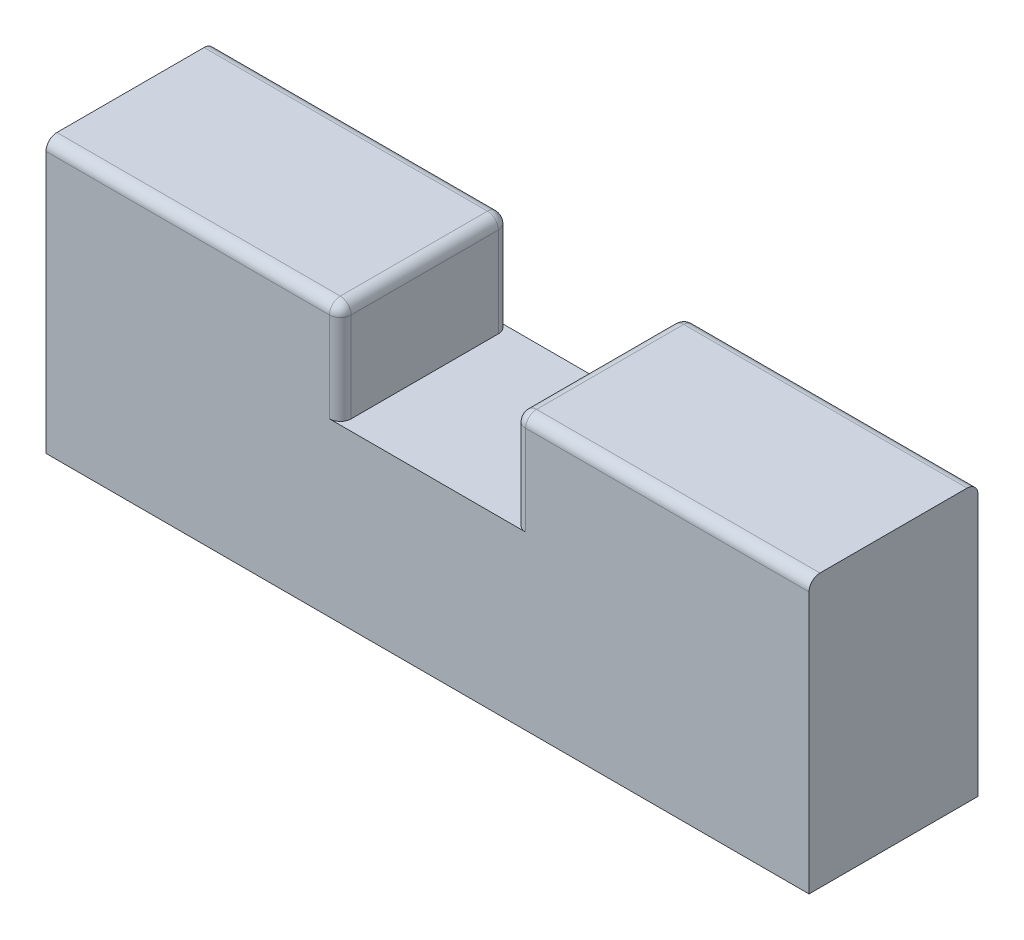
from build123d import *

# Parameters (mm, degrees)
SKETCH1_W           = 15.5
SKETCH1_H           = 25
BOSS_EXTRUDE1_DEPTH = 35
SKETCH2_W           = 16
SKETCH2_H           = 18.5
CUT_EXTRUDE1_DEPTH  = 16.5
FILLET1_R           = 1
FILLET2_R           = 1


with BuildPart() as part:
    # Sketch1 → Boss-Extrude1 (new body, symmetric)
    with BuildSketch(Plane(origin=(0, 0, 0), x_dir=(0, 0, -1), z_dir=(1, 0, 0))):
        Rectangle(SKETCH1_W, SKETCH1_H)
    extrude(amount=BOSS_EXTRUDE1_DEPTH, both=True)

    # Sketch2 → Cut-Extrude1 (cut, through all)
    with BuildSketch(Plane.XY.offset(7.75)):
        with Locations((0, 12.5)):
            Rectangle(SKETCH2_W, SKETCH2_H)
    extrude(amount=-CUT_EXTRUDE1_DEPTH, mode=Mode.SUBTRACT)

    # Fillet1
    fillet1_edges = [part.edges().sort_by_distance(p)[0] for p in [
        (8, 12.5, 0),
        (-8, 12.5, 0),
    ]]
    fillet(fillet1_edges, radius=FILLET1_R)

    # Fillet2
    fillet2_edges = [part.edges().sort_by_distance(p)[0] for p in [
        (-8, 7.375, 7.75),
        (8, 7.375, 7.75),
        (8, 7.375, -7.75),
        (-22, 12.5, 7.75),
        (-8.292893219, 12.207106781, 7.75),
        (8.292893219, 12.207106781, 7.75),
        (-22, 12.5, -7.75),
        (-8, 7.375, -7.75),
        (-8.292893219, 12.207106781, -7.75),
        (8.292893219, 12.207106781, -7.75),
        (22, 12.5, 7.75),
        (22, 12.5, -7.75),
    ]]
    fillet(fillet2_edges, radius=FILLET2_R)


solid = part.part
